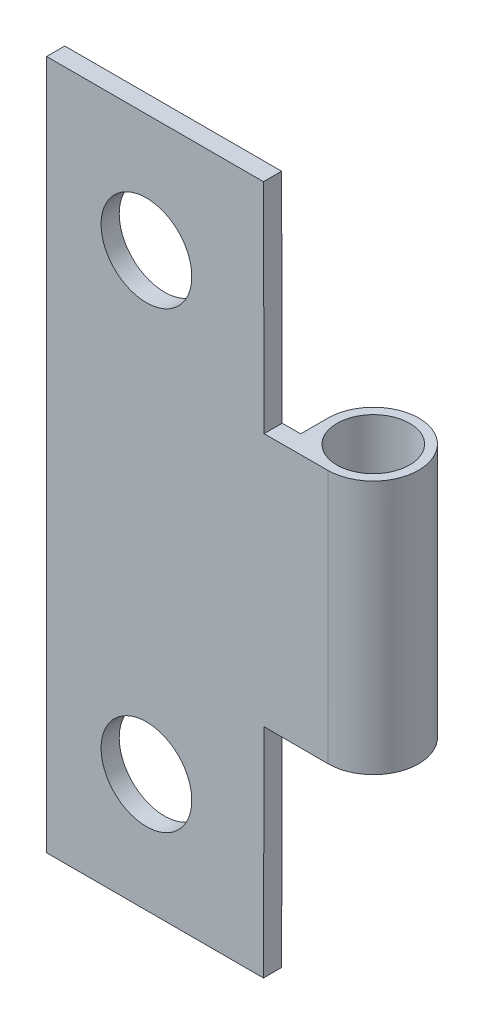
from build123d import *

# Parameters (mm, degrees)
SKETCH_1_W          = 13
SKETCH_1_H          = 38
EXTRUDE_1_DEPTH     = 1
SKETCH_2_R          = 2
EXTRUDE_2_DEPTH     = 38
CUT_EXTRUDE_2_DEPTH = 10
SKETCH_4_R          = 2.5
CUT_EXTRUDE_3_DEPTH = 2


with BuildPart() as part:
    # 草图1 → 凸台-拉伸1 (new body)
    with BuildSketch(Plane.XY):
        Rectangle(SKETCH_1_W, SKETCH_1_H)
    extrude(amount=EXTRUDE_1_DEPTH)

    # 草图2 → 凸台-拉伸2 (add)
    with BuildSketch(Plane(origin=(0, 19, 0), x_dir=(1, 0, 0), z_dir=(0, 1, 0))):
        with BuildLine():
            Line((6.5, -1), (9, -1))
            ThreePointArc((9, -1), (10.767766953, 3.267766953), (6.5, 1.5))
            Line((6.5, 1.5), (6.5, -1))
        make_face()
        with Locations((9, 1.5)):
            Circle(SKETCH_2_R, mode=Mode.SUBTRACT)
    extrude(amount=-EXTRUDE_2_DEPTH)

    # 草图3 → 切除-拉伸2 (cut)
    with BuildSketch(Plane.XY.offset(1)):
        Polygon((5.480957084, 6.99044612), (5.442845313, 20.990394244), (12.442819375, 21.00945013), (12.480931146, 7.009502005), align=None)
        Polygon((5.442845313, -20.990394244), (12.442819375, -21.00945013), (12.480931146, -7.009502005), (5.480957084, -6.99044612), align=None)
    extrude(amount=-CUT_EXTRUDE_2_DEPTH, mode=Mode.SUBTRACT)

    # 草图4 → 切除-拉伸3 (cut)
    with BuildSketch(Plane(origin=(0, 0, 0), x_dir=(-1, 0, 0), z_dir=(0, 0, -1))):
        with Locations((1, 12.5)):
            Circle(SKETCH_4_R)
        with Locations((1, -12.5)):
            Circle(SKETCH_4_R)
    extrude(amount=-CUT_EXTRUDE_3_DEPTH, mode=Mode.SUBTRACT)


solid = part.part
